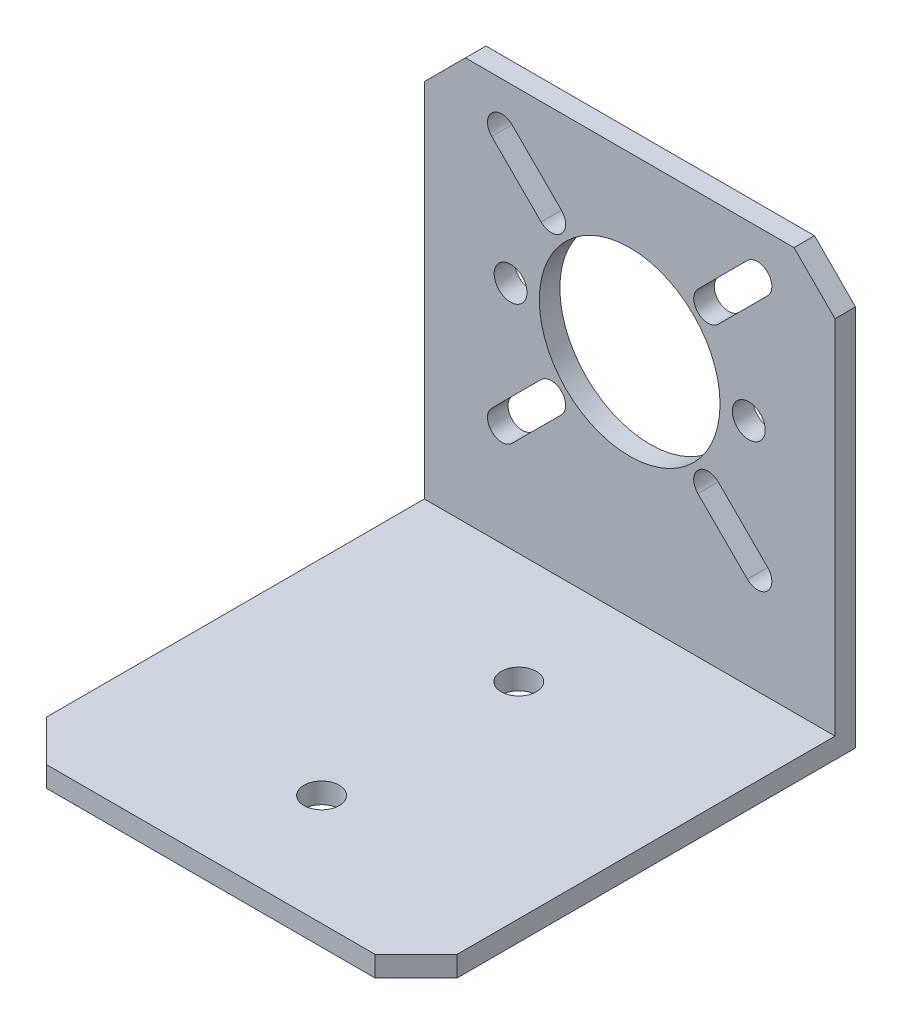
from build123d import *

# Parameters (mm, degrees)
SKETCH_14_W         = 50
SKETCH_14_H         = 51.5
SKETCH_14_R         = 11
SKETCH_14_R_2       = 2
EXTRUDE_1_DEPTH     = 2.5
SKETCH_16_W         = 50
SKETCH_16_H         = 2.5
EXTRUDE_2_DEPTH     = 51
SKETCH_17_R         = 2.15
CUT_EXTRUDE_1_DEPTH = 3.5
CHAMFER_1_SIZE      = 5


with BuildPart() as part:
    # 草图14 → 凸台-拉伸1 (new body)
    with BuildSketch(Plane.XY):
        Rectangle(SKETCH_14_W, SKETCH_14_H)
        with Locations((0, 4.75)):
            Circle(SKETCH_14_R, mode=Mode.SUBTRACT)
        with Locations((-14.5, 4.75)):
            Circle(SKETCH_14_R_2, mode=Mode.SUBTRACT)
        with Locations((14.5, 4.75)):
            Circle(SKETCH_14_R_2, mode=Mode.SUBTRACT)
        with BuildLine():
            Line((-14.318912319, 21.543786053), (-8.308504679, 15.533378413))
            ThreePointArc((-8.308504679, 15.533378413), (-8.308504679, 13.058504679), (-10.783378413, 13.058504679))
            Line((-10.783378413, 13.058504679), (-16.793786053, 19.068912319))
            ThreePointArc((-16.793786053, 19.068912319), (-16.793786053, 21.543786053), (-14.318912319, 21.543786053))
        make_face(mode=Mode.SUBTRACT)
        with BuildLine():
            Line((14.318912319, 21.543786053), (8.308504679, 15.533378413))
            ThreePointArc((8.308504679, 15.533378413), (8.308504679, 13.058504679), (10.783378413, 13.058504679))
            Line((10.783378413, 13.058504679), (16.793786053, 19.068912319))
            ThreePointArc((16.793786053, 19.068912319), (16.793786053, 21.543786053), (14.318912319, 21.543786053))
        make_face(mode=Mode.SUBTRACT)
        with BuildLine():
            Line((-14.318912319, -12.043786053), (-8.308504679, -6.033378413))
            ThreePointArc((-8.308504679, -6.033378413), (-8.308504679, -3.558504679), (-10.783378413, -3.558504679))
            Line((-10.783378413, -3.558504679), (-16.793786053, -9.568912319))
            ThreePointArc((-16.793786053, -9.568912319), (-16.793786053, -12.043786053), (-14.318912319, -12.043786053))
        make_face(mode=Mode.SUBTRACT)
        with BuildLine():
            Line((14.318912319, -12.043786053), (8.308504679, -6.033378413))
            ThreePointArc((8.308504679, -6.033378413), (8.308504679, -3.558504679), (10.783378413, -3.558504679))
            Line((10.783378413, -3.558504679), (16.793786053, -9.568912319))
            ThreePointArc((16.793786053, -9.568912319), (16.793786053, -12.043786053), (14.318912319, -12.043786053))
        make_face(mode=Mode.SUBTRACT)
    extrude(amount=EXTRUDE_1_DEPTH)

    # 草图16 → 凸台-拉伸2 (add)
    with BuildSketch(Plane.XY.offset(2.5)):
        with Locations((0, -24.5)):
            Rectangle(SKETCH_16_W, SKETCH_16_H)
    extrude(amount=EXTRUDE_2_DEPTH)

    # 草图17 → 切除-拉伸1 (cut, through all)
    with BuildSketch(Plane(origin=(0, -23.25, 0), x_dir=(1, 0, 0), z_dir=(0, 1, 0))):
        with Locations((0, -40)):
            Circle(SKETCH_17_R)
        with Locations((0, -16)):
            Circle(SKETCH_17_R)
    extrude(amount=-CUT_EXTRUDE_1_DEPTH, mode=Mode.SUBTRACT)

    # 倒角1
    chamfer_1_edges = [part.edges().sort_by_distance(p)[0] for p in [
        (-25, 25.75, 1.25),
        (25, 25.75, 1.25),
        (-25, -24.5, 53.5),
        (25, -24.5, 53.5),
    ]]
    chamfer(chamfer_1_edges, length=CHAMFER_1_SIZE)


solid = part.part
